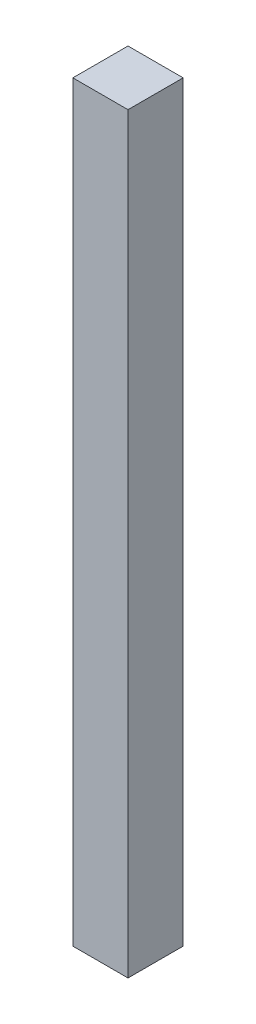
from build123d import *

# Parameters (mm, degrees)
SKETCH_34_W         = 44.1
SKETCH_34_H         = 35
EXTRUDE_1_DEPTH     = 20.9
SKETCH_35_W         = 8
SKETCH_35_H         = 8
EXTRUDE_2_DEPTH     = 109.1
SKETCH_36_W         = 3
SKETCH_36_H         = 3
EXTRUDE_3_DEPTH     = 109
SKETCH_37_W         = 130
SKETCH_37_H         = 130
CUT_EXTRUDE_1_DEPTH = 110
SKETCH_38_W         = 130
SKETCH_38_H         = 130
CUT_EXTRUDE_2_DEPTH = 21.9


with BuildPart() as part:
    # ｽｹｯﾁ34 → ﾎﾞｽ - 押し出し1 (new body)
    with BuildSketch(Plane(origin=(0, 0, 0), x_dir=(1, 0, 0), z_dir=(0, 1, 0))):
        Rectangle(SKETCH_34_W, SKETCH_34_H)
    extrude(amount=EXTRUDE_1_DEPTH)

    # ｽｹｯﾁ35 → ﾎﾞｽ - 押し出し2 (add)
    with BuildSketch(Plane(origin=(0, 20.9, 0), x_dir=(1, 0, 0), z_dir=(0, 1, 0))):
        Rectangle(SKETCH_35_W, SKETCH_35_H)
    extrude(amount=EXTRUDE_2_DEPTH)

    # ｽｹｯﾁ36 → ﾎﾞｽ - 押し出し3 (add)
    with BuildSketch(Plane(origin=(0, 130, 0), x_dir=(1, 0, 0), z_dir=(0, 1, 0))):
        Rectangle(SKETCH_36_W, SKETCH_36_H)
    extrude(amount=EXTRUDE_3_DEPTH)

    # ｽｹｯﾁ37 → ｶｯﾄ - 押し出し1 (cut, through all)
    with BuildSketch(Plane(origin=(0, 130, 0), x_dir=(1, 0, 0), z_dir=(0, 1, 0))):
        Rectangle(SKETCH_37_W, SKETCH_37_H)
    extrude(amount=CUT_EXTRUDE_1_DEPTH, mode=Mode.SUBTRACT)

    # ｽｹｯﾁ38 → ｶｯﾄ - 押し出し2 (cut, through all)
    with BuildSketch(Plane(origin=(0, 20.9, 0), x_dir=(1, 0, 0), z_dir=(0, 1, 0))):
        Rectangle(SKETCH_38_W, SKETCH_38_H)
    extrude(amount=-CUT_EXTRUDE_2_DEPTH, mode=Mode.SUBTRACT)


solid = part.part
